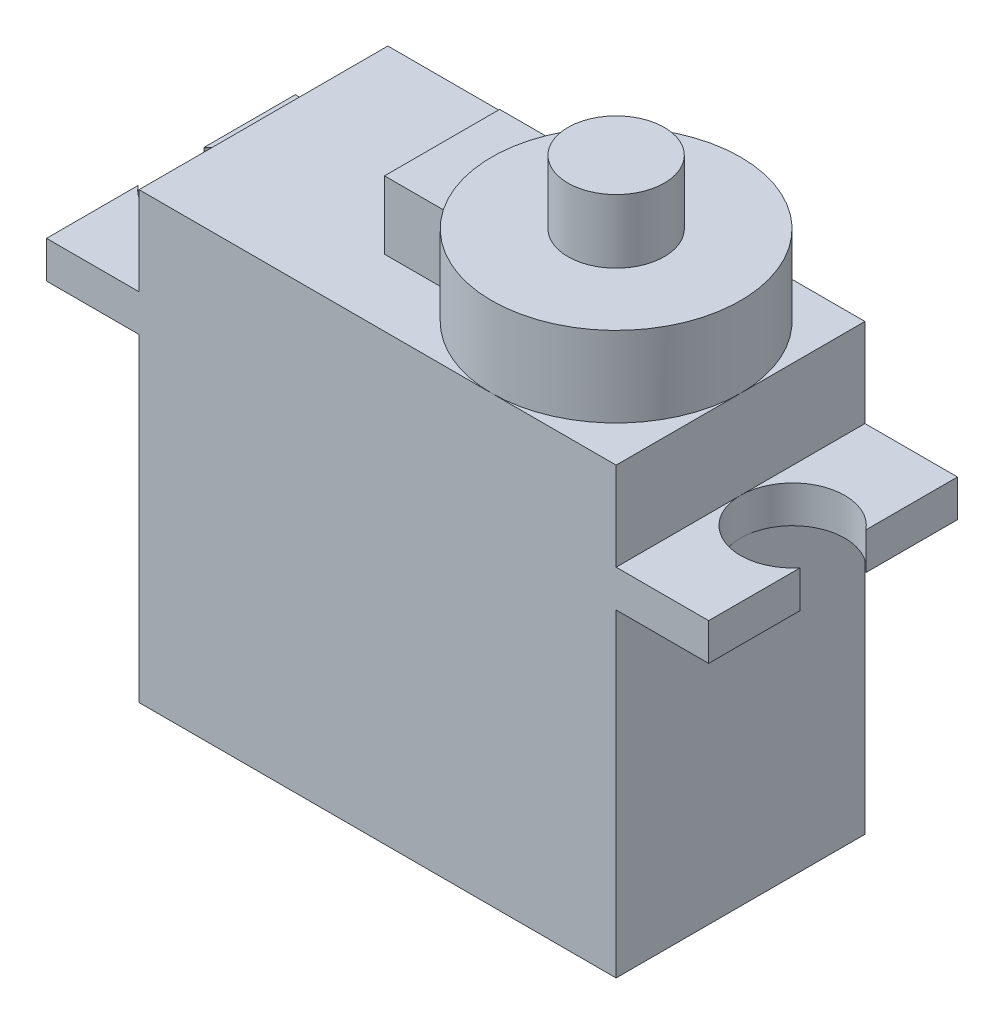
from build123d import *

# Parameters (mm, degrees)
SKETCH1_W           = 23.2
SKETCH1_H           = 12.1
BOSS_EXTRUDE1_DEPTH = 21.6
BOSS_EXTRUDE2_DEPTH = 1.8
SKETCH5_R           = 6.05
BOSS_EXTRUDE3_DEPTH = 3.9
SKETCH6_R           = 2.345
BOSS_EXTRUDE4_DEPTH = 3.1
SKETCH7_W           = 3.926136304
SKETCH7_H           = 5.6
BOSS_EXTRUDE5_DEPTH = 3.3


with BuildPart() as part:
    # Sketch1 → Boss-Extrude1 (new body)
    with BuildSketch(Plane(origin=(0, 0, 0), x_dir=(1, 0, 0), z_dir=(0, 1, 0))):
        Rectangle(SKETCH1_W, SKETCH1_H)
    extrude(amount=BOSS_EXTRUDE1_DEPTH)

    # Sketch3 → Boss-Extrude2 (add)
    with BuildSketch(Plane(origin=(0, 15.5, 0), x_dir=(-1, 0, 0), z_dir=(0, -1, 0))):
        with BuildLine():
            Line((-11.6, 2.8e-08), (-11.6, 6.05))
            Line((-11.6, 6.05), (-16.1, 6.05))
            Line((-16.1, 6.05), (-16.1, 1.6))
            ThreePointArc((-16.1, 1.6), (-13.285381067, 2.387990792), (-11.6, 2.8e-08))
        make_face()
        with BuildLine():
            Line((-11.6, -6.05), (-11.6, 2.8e-08))
            ThreePointArc((-11.6, 2.8e-08), (-13.28538104, -2.387990782), (-16.1, -1.6))
            Line((-16.1, -1.6), (-16.1, -6.05))
            Line((-16.1, -6.05), (-11.6, -6.05))
        make_face()
        with BuildLine():
            ThreePointArc((16.1, -1.6), (13.285381054, -2.387990787), (11.6, -1e-09))
            Line((11.6, -1e-09), (11.6, -6.05))
            Line((11.6, -6.05), (16.1, -6.05))
            Line((16.1, -6.05), (16.1, -1.6))
        make_face()
        with BuildLine():
            Line((16.1, 1.6), (16.1, 6.05))
            Line((16.1, 6.05), (11.6, 6.05))
            Line((11.6, 6.05), (11.6, -1e-09))
            ThreePointArc((11.6, -1e-09), (13.285381053, 2.387990787), (16.1, 1.6))
        make_face()
    extrude(amount=-BOSS_EXTRUDE2_DEPTH)

    # Sketch5 → Boss-Extrude3 (add)
    with BuildSketch(Plane(origin=(0, 21.6, 0), x_dir=(1, 0, 0), z_dir=(0, 1, 0))):
        with Locations((5.55, 0)):
            Circle(SKETCH5_R)
    extrude(amount=BOSS_EXTRUDE3_DEPTH)

    # Sketch6 → Boss-Extrude4 (add)
    with BuildSketch(Plane(origin=(0, 25.5, 0), x_dir=(1, 0, 0), z_dir=(0, 1, 0))):
        with Locations((5.55, 0)):
            Circle(SKETCH6_R)
    extrude(amount=BOSS_EXTRUDE4_DEPTH)

    # Sketch7 → Boss-Extrude5 (add)
    with BuildSketch(Plane(origin=(0, 21.6, 0), x_dir=(1, 0, 0), z_dir=(0, 1, 0))):
        with Locations((-0.95, 0)):
            Rectangle(SKETCH7_W, SKETCH7_H)
    extrude(amount=BOSS_EXTRUDE5_DEPTH)


solid = part.part
